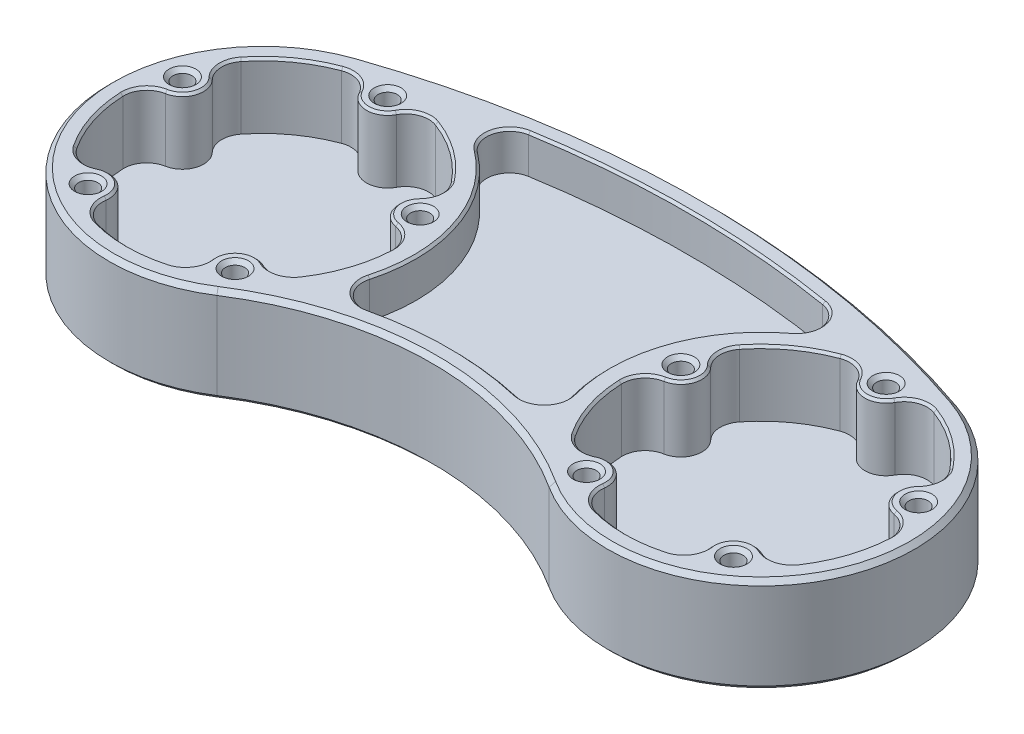
from build123d import *

# Parameters (mm, degrees)
SKETCH1_R                = 25.4
BOSS_EXTRUDE1_DEPTH      = 7.9375
SKETCH2_R                = 22.225
CUT_EXTRUDE1_DEPTH       = 10.795
CUT_EXTRUDE2_DEPTH       = 6.35
SKETCH4_R                = 3.4925
BOSS_EXTRUDE2_DEPTH      = 10.795
FILLET1_R                = 3.81
CIRPATTERN1_COUNT        = 5
FILLET1_OF_CIRPATTERN1_R = 3.81
SKETCH7_W                = 66.675
SKETCH7_H                = 50.8
CUT_EXTRUDE3_DEPTH       = 16.875
CHAMFER1_SIZE            = 0.381
CHAMFER2_SIZE            = 0.762


with BuildPart() as part:
    # Sketch1 → Boss-Extrude1 (new body, symmetric)
    with BuildSketch(Plane(origin=(0, 0, 0), x_dir=(1, 0, 0), z_dir=(0, 1, 0))):
        with Locations((-41.275, 0)):
            Circle(SKETCH1_R)
        with Locations((41.275, 0)):
            Circle(SKETCH1_R)
        with BuildLine():
            ThreePointArc((-49.53, 24.021136006), (-26.518933451, 20.674102157), (-15.875, 0))
            ThreePointArc((-15.875, 0), (-18.97453289, -12.159324269), (-27.516666667, -21.351071727))
            ThreePointArc((-27.516666667, -21.351071727), (0, -13.253215181), (27.516666667, -21.351071727))
            ThreePointArc((27.516666667, -21.351071727), (18.422626424, 11.087336106), (49.53, 24.021136006))
            ThreePointArc((49.53, 24.021136006), (0, 32.294319972), (-49.53, 24.021136006))
        make_face()
    extrude(amount=BOSS_EXTRUDE1_DEPTH, both=True)

    # Sketch2 → Cut-Extrude1 (cut)
    with BuildSketch(Plane(origin=(0, 7.9375, 0), x_dir=(1, 0, 0), z_dir=(0, 1, 0))):
        with Locations(Location((-41.275, 0, 0), (0, 0, 270))):  # turned: the seam where the file's is
            Circle(SKETCH2_R)
        with Locations(Location((41.275, 0, 0), (0, 0, 270))):  # turned: the seam where the file's is
            Circle(SKETCH2_R)
    extrude(amount=-CUT_EXTRUDE1_DEPTH, mode=Mode.SUBTRACT)

    # Sketch3 → Cut-Extrude2 (cut)
    with BuildSketch(Plane(origin=(0, 7.9375, 0), x_dir=(1, 0, 0), z_dir=(0, 1, 0))):
        with BuildLine():
            ThreePointArc((24.358789698, 27.117789533), (27.437637505, 24.264634778), (26.024446219, 20.31208038))
            ThreePointArc((26.024446219, 20.31208038), (17.234325709, 8.197925326), (16.791850935, -6.762796159))
            ThreePointArc((16.791850935, -6.762796159), (15.86741141, -10.416233495), (12.254364604, -11.487721051))
            ThreePointArc((12.254364604, -11.487721051), (0, -10.078215181), (-12.254364604, -11.487721051))
            ThreePointArc((-12.254364604, -11.487721051), (-15.86741141, -10.416233495), (-16.791850935, -6.762796159))
            ThreePointArc((-16.791850935, -6.762796159), (-17.234325709, 8.197925326), (-26.024446219, 20.31208038))
            ThreePointArc((-26.024446219, 20.31208038), (-27.437637505, 24.264634778), (-24.358789698, 27.117789533))
            ThreePointArc((-24.358789698, 27.117789533), (0, 29.119319972), (24.358789698, 27.117789533))
        make_face()
    cut_extrude2 = extrude(amount=-CUT_EXTRUDE2_DEPTH, mode=Mode.SUBTRACT)

    # Mirror1: Cut-Extrude2 across plane
    add(cut_extrude2.mirror(Plane.ZX), mode=Mode.SUBTRACT)

    # Sketch4 → Boss-Extrude2 (add)
    with BuildSketch(Plane(origin=(0, -2.8575, 0), x_dir=(1, 0, 0), z_dir=(0, 1, 0))):
        with Locations((-41.275, 20.701)):
            Circle(SKETCH4_R)
    boss_extrude2 = extrude(amount=BOSS_EXTRUDE2_DEPTH)

    # Fillet1
    fillet1_edges = [part.edges().sort_by_distance(p)[0] for p in [
        (-44.522319427, 2.54, -21.986485429),
        (-38.027680573, 2.54, -21.986485429),
    ]]
    fillet(fillet1_edges, radius=FILLET1_R)

    # Sketch5 → 1/8 (0.125) Diameter Hole1 (revolve, cut)
    with BuildSketch(Plane(origin=(-41.275, 7.9375, -20.701), x_dir=(0, 0, 1), z_dir=(1, 0, 0))):
        Polygon((0, 0), (0, 15.875), (2.2225, 15.875), (1.5875, 15.24), (1.5875, 0.635), (2.2225, 0), align=None)
    f_1_8_0_125_diameter_hole1 = revolve(axis=Axis((-41.275, 14.2875, -20.701), (0, -1, 0)), mode=Mode.SUBTRACT)

    # CirPattern1: Boss-Extrude2, 1/8 (0.125) Diameter Hole1 ×5 about axis
    cirpattern1_axis = Axis((-41.275, 0, 0), (0, 1, 0))
    add([boss_extrude2.rotate(cirpattern1_axis, i * 360 / CIRPATTERN1_COUNT) for i in range(1, CIRPATTERN1_COUNT)])
    add([f_1_8_0_125_diameter_hole1.rotate(cirpattern1_axis, i * 360 / CIRPATTERN1_COUNT) for i in range(1, CIRPATTERN1_COUNT)], mode=Mode.SUBTRACT)

    # Fillet1 of CirPattern1
    fillet1_of_cirpattern1_edges = [part.edges().sort_by_distance(p)[0] for p in [
        (-63.188867127, 2.54, -3.705813343),
        (-61.181913349, 2.54, -9.882581946),
        (-51.571195283, 2.54, 19.696166828),
        (-56.825468488, 2.54, 15.87871389),
        (-25.724531512, 2.54, 15.87871389),
        (-30.978804717, 2.54, 19.696166828),
        (-21.368086651, 2.54, -9.882581946),
        (-19.361132873, 2.54, -3.705813343),
    ]]
    fillet(fillet1_of_cirpattern1_edges, radius=FILLET1_OF_CIRPATTERN1_R)

    # Sketch7 → Cut-Extrude3 (cut, through all)
    with BuildSketch(Plane(origin=(0, 7.9375, 0), x_dir=(1, 0, 0), z_dir=(0, 1, 0))):
        with Locations((33.3375, 0)):
            Rectangle(SKETCH7_W, SKETCH7_H)
    extrude(amount=-CUT_EXTRUDE3_DEPTH, mode=Mode.SUBTRACT)

    # Mirror8: part across plane


with BuildPart() as part_1:
    add(part.part)
    add(part.part.mirror(Plane(origin=(0, -7.9375, -25.4), x_dir=(0, 0, 1), z_dir=(-1, 0, 0))))

    # Chamfer1
    chamfer1_edges = [part_1.edges().sort_by_distance(p)[0] for p in [
        (-57.641256061, 7.9375, -5.317718948),
        (-62.412231075, 7.9375, 6.8679027),
        (-62.647167248, 7.9375, -1.590554899),
        (-59.500351223, 7.9375, -11.275458774),
        (-51.389902514, 7.9375, 13.921968948),
        (-41.275, 7.9375, 22.225),
        (-49.392070488, 7.9375, 19.834630434),
        (-57.630541797, 7.9375, 13.849030662),
        (-31.160097486, 7.9375, 13.921968948),
        (-20.137768925, 7.9375, 6.8679027),
        (-24.919458203, 7.9375, 13.849030662),
        (-33.157929512, 7.9375, 19.834630434),
        (-24.908743939, 7.9375, -5.317718948),
        (-28.211472768, 7.9375, -17.9804027),
        (-23.049648777, 7.9375, -11.275458774),
        (-19.902832752, 7.9375, -1.590554899),
        (27.437637505, -7.9375, -24.264634778),
        (27.437637505, 7.9375, -24.264634778),
        (0, 7.9375, -29.119319972),
        (-27.437637505, 7.9375, -24.264634778),
        (28.211472768, 7.9375, -17.9804027),
        (-17.234325709, 7.9375, -8.197925326),
        (54.338527232, 7.9375, -17.9804027),
        (62.412231075, 7.9375, 6.8679027),
        (41.275, 7.9375, 22.225),
        (20.137768925, 7.9375, 6.8679027),
        (17.234325709, 7.9375, -8.197925326),
        (15.86741141, 7.9375, 10.416233495),
        (-15.86741141, 7.9375, 10.416233495),
        (17.234325709, -7.9375, -8.197925326),
        (0, 7.9375, 10.078215181),
        (15.86741141, -7.9375, 10.416233495),
        (41.275, 7.9375, -17.2085),
        (46.366655285, 7.9375, -20.817647423),
        (36.183344715, 7.9375, -20.817647423),
        (57.641256061, 7.9375, -5.317718948),
        (51.389902514, 7.9375, 13.921968948),
        (31.160097486, 7.9375, 13.921968948),
        (24.908743939, 7.9375, -5.317718948),
        (62.647167248, 7.9375, -1.590554899),
        (59.500351223, 7.9375, -11.275458774),
        (49.392070488, 7.9375, 19.834630434),
        (57.630541797, 7.9375, 13.849030662),
        (24.919458203, 7.9375, 13.849030662),
        (33.157929512, 7.9375, 19.834630434),
        (23.049648777, 7.9375, -11.275458774),
        (19.902832752, 7.9375, -1.590554899),
        (0, -7.9375, -29.119319972),
        (-27.437637505, -7.9375, -24.264634778),
        (-17.234325709, -7.9375, -8.197925326),
        (-15.86741141, -7.9375, 10.416233495),
        (0, -7.9375, 10.078215181),
        (-41.275, 7.9375, -17.2085),
        (-54.338527232, 7.9375, -17.9804027),
        (-46.366655285, 7.9375, -20.817647423),
        (-36.183344715, 7.9375, -20.817647423),
    ]]
    chamfer(chamfer1_edges, length=CHAMFER1_SIZE)

    # Chamfer2
    chamfer2_edges = [part_1.edges().sort_by_distance(p)[0] for p in [
        (0, 7.9375, -32.294319972),
        (64.127373576, -7.9375, 11.087336106),
        (64.127373576, 7.9375, 11.087336106),
        (-64.127373576, 7.9375, 11.087336106),
        (0, -7.9375, -32.294319972),
        (0, -7.9375, 13.253215181),
        (-64.127373576, -7.9375, 11.087336106),
        (0, 7.9375, 13.253215181),
    ]]
    chamfer(chamfer2_edges, length=CHAMFER2_SIZE)


solid = part_1.part
